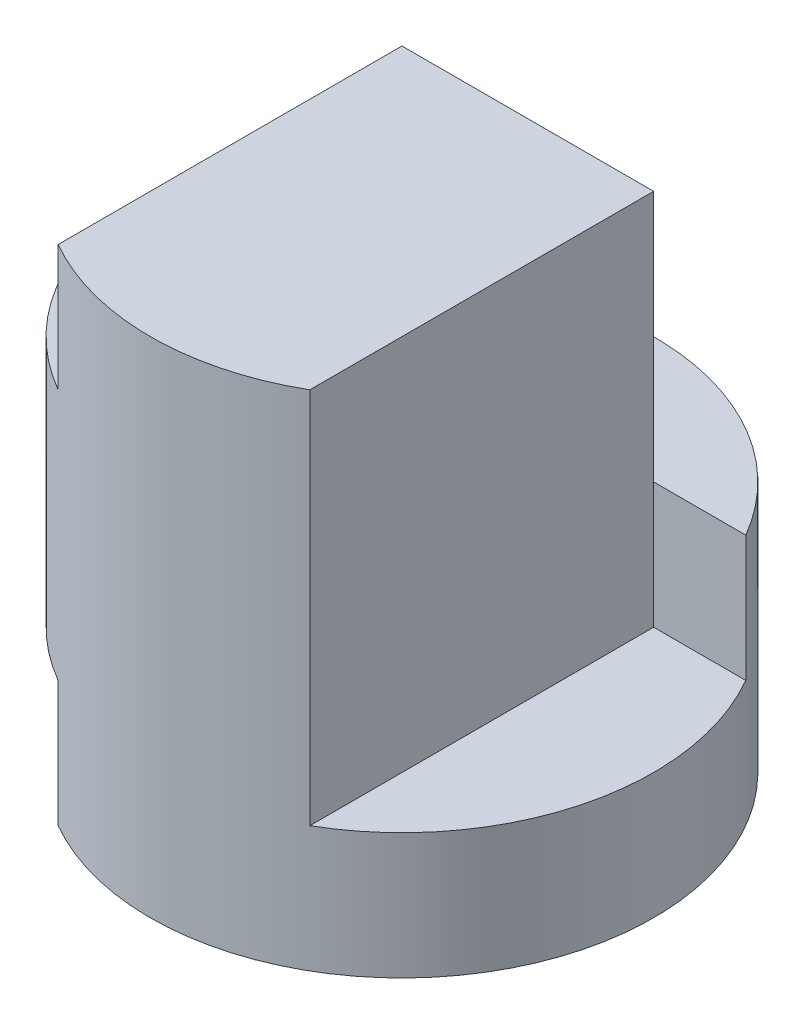
from build123d import *

# Parameters (mm, degrees)
SKETCH1_R               = 2
BOSS_EXTRUDE1_DEPTH     = 4
SKETCH2_W               = 1
SKETCH2_H               = 1
SKETCH2_H_2             = 3
CUT_EXTRUDE1_DEPTH      = 4
CUT_EXTRUDE1_DEPTH_BACK = 1
CUT_EXTRUDE2_DEPTH      = 2


with BuildPart() as part:
    # Sketch1 → Boss-Extrude1 (new body)
    with BuildSketch(Plane(origin=(0, 0, 0), x_dir=(1, 0, 0), z_dir=(0, 1, 0))):
        Circle(SKETCH1_R)
    extrude(amount=BOSS_EXTRUDE1_DEPTH)

    # Sketch2 → Cut-Extrude1 (cut, two sides)
    with BuildSketch(Plane.XY) as cut_extrude1_sk:
        with Locations((-1.5, 3.5)):
            Rectangle(SKETCH2_W, SKETCH2_H)
        with Locations((1.5, 2.5)):
            Rectangle(SKETCH2_W, SKETCH2_H_2)
        with Locations((-1.5, 0.5)):
            Rectangle(SKETCH2_W, SKETCH2_H)
    extrude(amount=CUT_EXTRUDE1_DEPTH, mode=Mode.SUBTRACT)
    extrude(cut_extrude1_sk.sketch, amount=-CUT_EXTRUDE1_DEPTH_BACK, mode=Mode.SUBTRACT)

    # Sketch3 → Cut-Extrude2 (cut)
    with BuildSketch(Plane(origin=(0, 4, 0), x_dir=(1, 0, 0), z_dir=(0, 1, 0))):
        with BuildLine():
            Line((-1.732050808, 1), (1.732050808, 1))
            ThreePointArc((1.732050808, 1), (0, 2), (-1.732050808, 1))
        make_face()
    extrude(amount=-CUT_EXTRUDE2_DEPTH, mode=Mode.SUBTRACT)


solid = part.part
